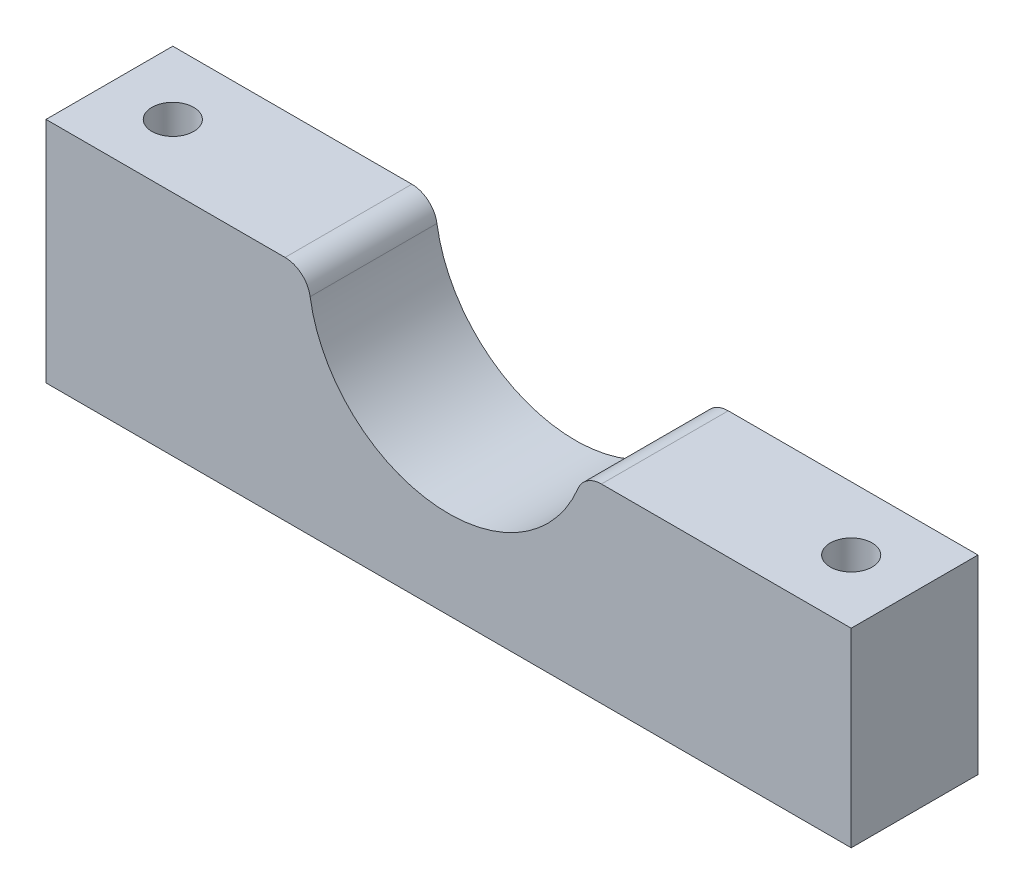
from build123d import *

# Parameters (mm, degrees)
EXTRUDE_1_DEPTH = 10
M4X0_71_D       = 3.3
FILLET_2_R      = 2


with BuildPart() as part:
    # Эскиз1 → Бобышка-Вытянуть1 (new body)
    with BuildSketch(Plane.XY):
        with BuildLine():
            Line((-31.75, 0), (-11.05, 0))
            ThreePointArc((-11.05, 0), (-1.514286407, -10.945749708), (10.634965914, -3))
            Line((10.634965914, -3), (31.75, -3))
            Line((31.75, -3), (31.75, -18))
            Line((31.75, -18), (-31.75, -18))
            Line((-31.75, -18), (-31.75, 0))
        make_face()
    extrude(amount=EXTRUDE_1_DEPTH)

    # Отверстие обработанное метчиком M4x0.71 (through all)
    with Locations(Plane(origin=(0, -18, 0), x_dir=(-1, 0, 0), z_dir=(0, -1, 0))):
        with Locations((26.75, -5), (-26.75, -5)):
            Hole(M4X0_71_D / 2)

    # Скругление2
    fillet_2_edges = [part.edges().sort_by_distance(p)[0] for p in [
        (-11.05, 0, 5),
        (10.634965914, -3, 5),
    ]]
    fillet(fillet_2_edges, radius=FILLET_2_R)


solid = part.part
